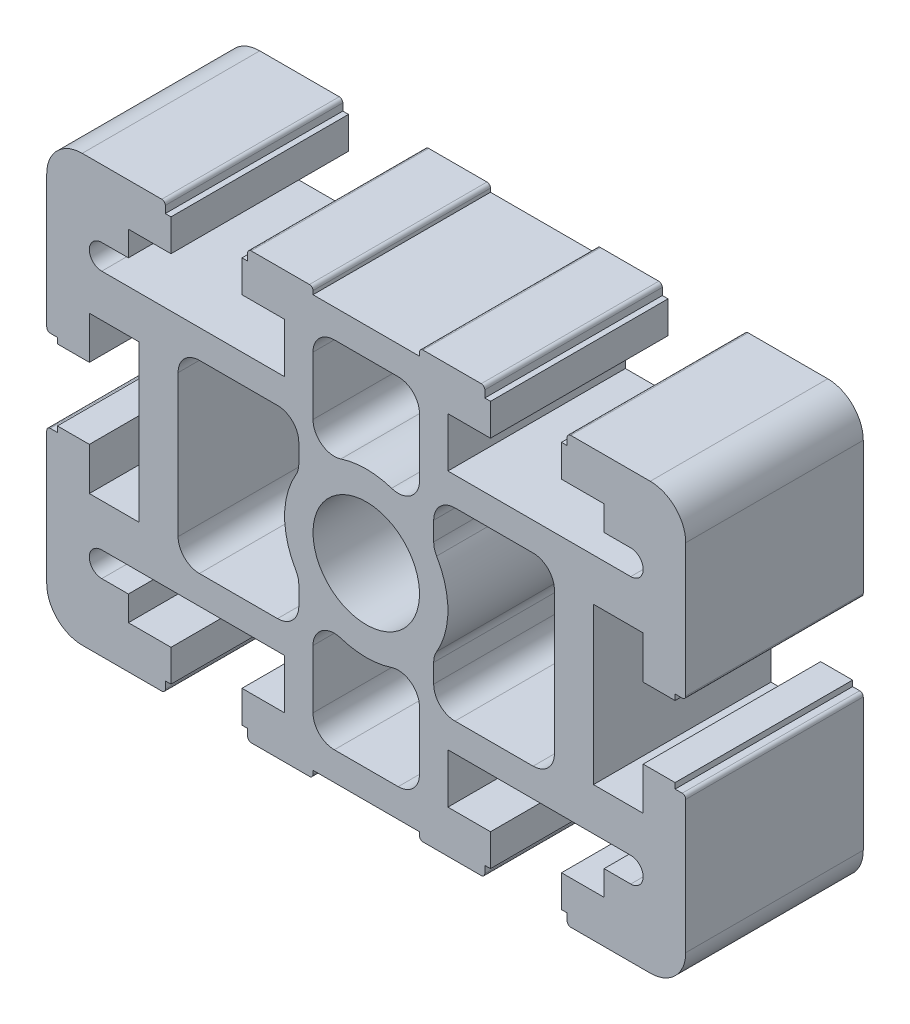
from build123d import *

# Parameters (mm, degrees)
SKETCH1_R           = 7.4999849
BOSS_EXTRUDE1_DEPTH = 25


with BuildPart() as part:
    # Sketch1 → Boss-Extrude1 (new body)
    with BuildSketch(Plane.XY):
        with BuildLine():
            Line((28.798743476, -29.99996723), (39.998722185, -29.99996723))
            ThreePointArc((39.998722185, -29.99996723), (43.534246379, -28.535505159), (44.99870845, -24.999980965))
            Line((44.99870845, -24.999980965), (44.99870845, -6.300013256))
            ThreePointArc((44.99870845, -6.300013256), (44.852262243, -5.946460836), (44.498709824, -5.800014629))
            Line((44.498709824, -5.800014629), (43.49871145, -5.800014629))
            Line((43.49871145, -5.800014629), (43.49871145, -5.00001723))
            Line((43.49871145, -5.00001723), (38.99872045, -5.00001723))
            Line((38.99872045, -5.00001723), (38.99872045, -11.00000523))
            Line((38.99872045, -11.00000523), (31.99873445, -11.00000523))
            Line((31.99873445, -11.00000523), (31.99873445, 11.00000523))
            Line((31.99873445, 11.00000523), (38.99872045, 11.00000523))
            Line((38.99872045, 11.00000523), (38.99872045, 5.00001723))
            Line((38.99872045, 5.00001723), (43.49871145, 5.00001723))
            Line((43.49871145, 5.00001723), (43.49871145, 5.800014629))
            Line((43.49871145, 5.800014629), (44.498709824, 5.800014629))
            ThreePointArc((44.498709824, 5.800014629), (44.852262243, 5.946460836), (44.99870845, 6.300013256))
            Line((44.99870845, 6.300013256), (44.99870845, 24.999980965))
            ThreePointArc((44.99870845, 24.999980965), (43.534246379, 28.535505159), (39.998722185, 29.99996723))
            Line((39.998722185, 29.99996723), (28.798743476, 29.99996723))
            ThreePointArc((28.798743476, 29.99996723), (28.445191057, 29.853521023), (28.29874485, 29.499968604))
            Line((28.29874485, 29.499968604), (28.29874485, 28.499970229))
            Line((28.29874485, 28.499970229), (27.49874345, 28.499970229))
            Line((27.49874345, 28.499970229), (27.49874345, 23.999979229))
            Line((27.49874345, 23.999979229), (33.49873145, 23.999979229))
            Line((33.49873145, 23.999979229), (33.49873145, 20.499986229))
            Line((33.49873145, 20.499986229), (37.251126945, 20.499986229))
            ThreePointArc((37.251126945, 20.499986229), (39.001123445, 18.749989729), (37.251126945, 16.999993229))
            Line((37.251126945, 16.999993229), (11.49877545, 16.999993229))
            Line((11.49877545, 16.999993229), (11.49877545, 23.999979229))
            Line((11.49877545, 23.999979229), (17.49876345, 23.999979229))
            Line((17.49876345, 23.999979229), (17.49876345, 28.499970229))
            Line((17.49876345, 28.499970229), (16.69876605, 28.499970229))
            Line((16.69876605, 28.499970229), (16.69876605, 29.49996775))
            ThreePointArc((16.69876605, 29.49996775), (16.552319593, 29.853520773), (16.19876657, 29.99996723))
            Line((16.19876657, 29.99996723), (7.999983464, 29.99996723))
            ThreePointArc((7.999983464, 29.99996723), (7.646431045, 29.853521023), (7.499984838, 29.499968604))
            Line((7.499984838, 29.499968604), (7.499984838, 28.99995862))
            Line((7.499984838, 28.99995862), (-7.499984838, 28.99995862))
            Line((-7.499984838, 28.99995862), (-7.499984838, 29.499968604))
            ThreePointArc((-7.499984838, 29.499968604), (-7.646431045, 29.853521023), (-7.999983464, 29.99996723))
            Line((-7.999983464, 29.99996723), (-16.19876657, 29.99996723))
            ThreePointArc((-16.19876657, 29.99996723), (-16.552319593, 29.853520773), (-16.69876605, 29.49996775))
            Line((-16.69876605, 29.49996775), (-16.69876605, 28.499970229))
            Line((-16.69876605, 28.499970229), (-17.49876345, 28.499970229))
            Line((-17.49876345, 28.499970229), (-17.49876345, 23.999979229))
            Line((-17.49876345, 23.999979229), (-11.49877545, 23.999979229))
            Line((-11.49877545, 23.999979229), (-11.49877545, 16.999993229))
            Line((-11.49877545, 16.999993229), (-37.251126945, 16.999993229))
            ThreePointArc((-37.251126945, 16.999993229), (-39.001123445, 18.749989729), (-37.251126945, 20.499986229))
            Line((-37.251126945, 20.499986229), (-33.49873145, 20.499986229))
            Line((-33.49873145, 20.499986229), (-33.49873145, 23.999979229))
            Line((-33.49873145, 23.999979229), (-27.49874345, 23.999979229))
            Line((-27.49874345, 23.999979229), (-27.49874345, 28.499970229))
            Line((-27.49874345, 28.499970229), (-28.29874485, 28.499970229))
            Line((-28.29874485, 28.499970229), (-28.29874485, 29.499968604))
            ThreePointArc((-28.29874485, 29.499968604), (-28.445191057, 29.853521023), (-28.798743476, 29.99996723))
            Line((-28.798743476, 29.99996723), (-39.998722185, 29.99996723))
            ThreePointArc((-39.998722185, 29.99996723), (-43.534246379, 28.535505159), (-44.99870845, 24.999980965))
            Line((-44.99870845, 24.999980965), (-44.99870845, 6.300013256))
            ThreePointArc((-44.99870845, 6.300013256), (-44.852262243, 5.946460836), (-44.498709824, 5.800014629))
            Line((-44.498709824, 5.800014629), (-43.49871145, 5.800014629))
            Line((-43.49871145, 5.800014629), (-43.49871145, 5.00001723))
            Line((-43.49871145, 5.00001723), (-38.99872045, 5.00001723))
            Line((-38.99872045, 5.00001723), (-38.99872045, 11.00000523))
            Line((-38.99872045, 11.00000523), (-31.99873445, 11.00000523))
            Line((-31.99873445, 11.00000523), (-31.99873445, -11.00000523))
            Line((-31.99873445, -11.00000523), (-38.99872045, -11.00000523))
            Line((-38.99872045, -11.00000523), (-38.99872045, -5.00001723))
            Line((-38.99872045, -5.00001723), (-43.49871145, -5.00001723))
            Line((-43.49871145, -5.00001723), (-43.49871145, -5.800014629))
            Line((-43.49871145, -5.800014629), (-44.498709824, -5.800014629))
            ThreePointArc((-44.498709824, -5.800014629), (-44.852262243, -5.946460836), (-44.99870845, -6.300013256))
            Line((-44.99870845, -6.300013256), (-44.99870845, -24.999980965))
            ThreePointArc((-44.99870845, -24.999980965), (-43.534246379, -28.535505159), (-39.998722185, -29.99996723))
            Line((-39.998722185, -29.99996723), (-28.798743476, -29.99996723))
            ThreePointArc((-28.798743476, -29.99996723), (-28.445191057, -29.853521023), (-28.29874485, -29.499968604))
            Line((-28.29874485, -29.499968604), (-28.29874485, -28.499970229))
            Line((-28.29874485, -28.499970229), (-27.49874345, -28.499970229))
            Line((-27.49874345, -28.499970229), (-27.49874345, -23.999979229))
            Line((-27.49874345, -23.999979229), (-33.49873145, -23.999979229))
            Line((-33.49873145, -23.999979229), (-33.49873145, -20.499986229))
            Line((-33.49873145, -20.499986229), (-37.251126945, -20.499986229))
            ThreePointArc((-37.251126945, -20.499986229), (-39.001123445, -18.749989729), (-37.251126945, -16.999993229))
            Line((-37.251126945, -16.999993229), (-11.49877545, -16.999993229))
            Line((-11.49877545, -16.999993229), (-11.49877545, -23.999979229))
            Line((-11.49877545, -23.999979229), (-17.49876345, -23.999979229))
            Line((-17.49876345, -23.999979229), (-17.49876345, -28.499970229))
            Line((-17.49876345, -28.499970229), (-16.69876605, -28.499970229))
            Line((-16.69876605, -28.499970229), (-16.69876605, -29.49996775))
            ThreePointArc((-16.69876605, -29.49996775), (-16.552319593, -29.853520773), (-16.19876657, -29.99996723))
            Line((-16.19876657, -29.99996723), (-7.999983464, -29.99996723))
            ThreePointArc((-7.999983464, -29.99996723), (-7.646431045, -29.853521023), (-7.499984838, -29.499968604))
            Line((-7.499984838, -29.499968604), (-7.499984838, -28.99995862))
            Line((-7.499984838, -28.99995862), (7.499984838, -28.99995862))
            Line((7.499984838, -28.99995862), (7.499984838, -29.499968604))
            ThreePointArc((7.499984838, -29.499968604), (7.646431045, -29.853521023), (7.999983464, -29.99996723))
            Line((7.999983464, -29.99996723), (16.19876657, -29.99996723))
            ThreePointArc((16.19876657, -29.99996723), (16.552319593, -29.853520773), (16.69876605, -29.49996775))
            Line((16.69876605, -29.49996775), (16.69876605, -28.499970229))
            Line((16.69876605, -28.499970229), (17.49876345, -28.499970229))
            Line((17.49876345, -28.499970229), (17.49876345, -23.999979229))
            Line((17.49876345, -23.999979229), (11.49877545, -23.999979229))
            Line((11.49877545, -23.999979229), (11.49877545, -16.999993229))
            Line((11.49877545, -16.999993229), (37.251126945, -16.999993229))
            ThreePointArc((37.251126945, -16.999993229), (39.001123445, -18.749989729), (37.251126945, -20.499986229))
            Line((37.251126945, -20.499986229), (33.49873145, -20.499986229))
            Line((33.49873145, -20.499986229), (33.49873145, -23.999979229))
            Line((33.49873145, -23.999979229), (27.49874345, -23.999979229))
            Line((27.49874345, -23.999979229), (27.49874345, -28.499970229))
            Line((27.49874345, -28.499970229), (28.29874485, -28.499970229))
            Line((28.29874485, -28.499970229), (28.29874485, -29.499968604))
            ThreePointArc((28.29874485, -29.499968604), (28.445191057, -29.853521023), (28.798743476, -29.99996723))
        make_face()
        Circle(SKETCH1_R, mode=Mode.SUBTRACT)
        with BuildLine():
            Line((7.498782838, -13.784434919), (7.498782838, -21.999974861))
            ThreePointArc((7.498782838, -21.999974861), (6.620105596, -24.121289377), (4.498791079, -24.99996662))
            Line((4.498791079, -24.99996662), (-4.498791079, -24.99996662))
            ThreePointArc((-4.498791079, -24.99996662), (-6.620105596, -24.121289377), (-7.498782838, -21.999974861))
            Line((-7.498782838, -21.999974861), (-7.498782838, -13.784434919))
            ThreePointArc((-7.498782838, -13.784434919), (-6.26055251, -11.356235576), (-3.568006565, -10.932487146))
            ThreePointArc((-3.568006565, -10.932487146), (0, -11.499997654), (3.568006565, -10.932487146))
            ThreePointArc((3.568006565, -10.932487146), (6.26055251, -11.356235576), (7.498782838, -13.784434919))
        make_face(mode=Mode.SUBTRACT)
        with BuildLine():
            Line((-7.498782838, 13.784434919), (-7.498782838, 21.999974861))
            ThreePointArc((-7.498782838, 21.999974861), (-6.620105596, 24.121289377), (-4.498791079, 24.99996662))
            Line((-4.498791079, 24.99996662), (4.498791079, 24.99996662))
            ThreePointArc((4.498791079, 24.99996662), (6.620105596, 24.121289377), (7.498782838, 21.999974861))
            Line((7.498782838, 21.999974861), (7.498782838, 13.784434919))
            ThreePointArc((7.498782838, 13.784434919), (6.26055251, 11.356235576), (3.568006565, 10.932487146))
            ThreePointArc((3.568006565, 10.932487146), (0, 11.499997654), (-3.568006565, 10.932487146))
            ThreePointArc((-3.568006565, 10.932487146), (-6.26055251, 11.356235576), (-7.498782838, 13.784434919))
        make_face(mode=Mode.SUBTRACT)
        with BuildLine():
            Line((26.498750816, 9.999999861), (26.498750816, -9.999999861))
            ThreePointArc((26.498750816, -9.999999861), (25.620073573, -12.121314377), (23.498759057, -12.99999162))
            Line((23.498759057, -12.99999162), (12.498776575, -12.99999162))
            ThreePointArc((12.498776575, -12.99999162), (10.377462058, -12.121314377), (9.498784816, -9.999999861))
            Line((9.498784816, -9.999999861), (9.498784816, -7.350508853))
            ThreePointArc((9.498784816, -7.350508853), (9.604145594, -6.562432144), (9.912827344, -5.829710252))
            ThreePointArc((9.912827344, -5.829710252), (11.499985547, 0), (9.912827344, 5.829710252))
            ThreePointArc((9.912827344, 5.829710252), (9.604145594, 6.562432144), (9.498784816, 7.350508853))
            Line((9.498784816, 7.350508853), (9.498784816, 9.999999861))
            ThreePointArc((9.498784816, 9.999999861), (10.377462058, 12.121314377), (12.498776575, 12.99999162))
            Line((12.498776575, 12.99999162), (23.498759057, 12.99999162))
            ThreePointArc((23.498759057, 12.99999162), (25.620073573, 12.121314377), (26.498750816, 9.999999861))
        make_face(mode=Mode.SUBTRACT)
        with BuildLine():
            Line((-9.498784816, -7.350508853), (-9.498784816, -9.999999861))
            ThreePointArc((-9.498784816, -9.999999861), (-10.377462058, -12.121314377), (-12.498776575, -12.99999162))
            Line((-12.498776575, -12.99999162), (-23.498759057, -12.99999162))
            ThreePointArc((-23.498759057, -12.99999162), (-25.620073573, -12.121314377), (-26.498750816, -9.999999861))
            Line((-26.498750816, -9.999999861), (-26.498750816, 9.999999861))
            ThreePointArc((-26.498750816, 9.999999861), (-25.620073573, 12.121314377), (-23.498759057, 12.99999162))
            Line((-23.498759057, 12.99999162), (-12.498776575, 12.99999162))
            ThreePointArc((-12.498776575, 12.99999162), (-10.377462058, 12.121314377), (-9.498784816, 9.999999861))
            Line((-9.498784816, 9.999999861), (-9.498784816, 7.350508853))
            ThreePointArc((-9.498784816, 7.350508853), (-9.604145594, 6.562432144), (-9.912827344, 5.829710252))
            ThreePointArc((-9.912827344, 5.829710252), (-11.499985547, 0), (-9.912827344, -5.829710252))
            ThreePointArc((-9.912827344, -5.829710252), (-9.604145594, -6.562432144), (-9.498784816, -7.350508853))
        make_face(mode=Mode.SUBTRACT)
    extrude(amount=-BOSS_EXTRUDE1_DEPTH)


solid = part.part
